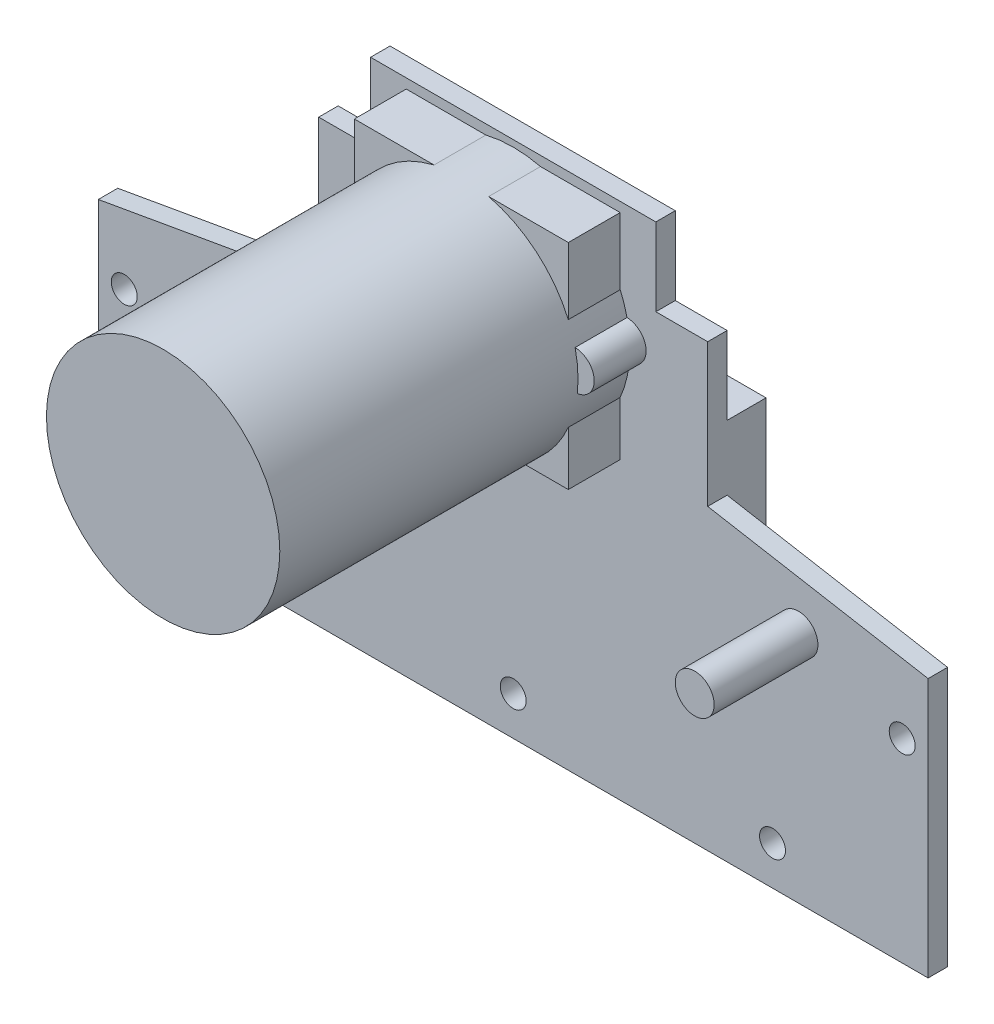
from build123d import *

# Parameters (mm, degrees)
SKETCH1_W           = 30
SKETCH1_H           = 11
SKETCH1_W_2         = 22
SKETCH1_H_2         = 6
BOSS_EXTRUDE1_DEPTH = 1.5
SKETCH2_R           = 1
CUT_EXTRUDE1_DEPTH  = 5
SKETCH3_R           = 9
BOSS_EXTRUDE2_DEPTH = 27
SKETCH5_W           = 28
SKETCH5_H           = 21
BOSS_EXTRUDE3_DEPTH = 3
SKETCH6_R           = 1.5
BOSS_EXTRUDE4_DEPTH = 8
SKETCH7_R           = 1.5
SKETCH7_W           = 16.5
SKETCH7_H           = 16.5
BOSS_EXTRUDE5_DEPTH = 4


with BuildPart() as part:
    # Sketch1 → Boss-Extrude1 (new body)
    with BuildSketch(Plane.XY):
        Polygon((32, 0), (32, 20), (15, 23), (-15, 23), (-32, 20), (-32, 0), align=None)
        with Locations((0, 28.5)):
            Rectangle(SKETCH1_W, SKETCH1_H)
        with Locations((0, 37)):
            Rectangle(SKETCH1_W_2, SKETCH1_H_2)
    extrude(amount=BOSS_EXTRUDE1_DEPTH)

    # Sketch2 → Cut-Extrude1 (cut)
    with BuildSketch(Plane.XY.offset(1.5)):
        with Locations((20, 3)):
            Circle(SKETCH2_R)
        with Locations((0, 3)):
            Circle(SKETCH2_R)
        with Locations((-20, 3)):
            Circle(SKETCH2_R)
        with Locations((-30, 15)):
            Circle(SKETCH2_R)
        with Locations((30, 15)):
            Circle(SKETCH2_R)
    extrude(amount=-CUT_EXTRUDE1_DEPTH, mode=Mode.SUBTRACT)

    # Sketch3 → Boss-Extrude2 (add)
    with BuildSketch(Plane.XY.offset(1.5)):
        with Locations((0, 30.5)):
            Circle(SKETCH3_R)
    extrude(amount=BOSS_EXTRUDE2_DEPTH)

    # Sketch5 → Boss-Extrude3 (add)
    with BuildSketch(Plane(origin=(0, 0, 0), x_dir=(-1, 0, 0), z_dir=(0, 0, -1))):
        with Locations((-1, 17.5)):
            Rectangle(SKETCH5_W, SKETCH5_H)
    extrude(amount=BOSS_EXTRUDE3_DEPTH)

    # Sketch6 → Boss-Extrude4 (add)
    with BuildSketch(Plane.XY.offset(1.5)):
        with Locations((22, 18)):
            Circle(SKETCH6_R)
        with Locations((-22, 18)):
            Circle(SKETCH6_R)
    extrude(amount=BOSS_EXTRUDE4_DEPTH)

    # Sketch7 → Boss-Extrude5 (add)
    with BuildSketch(Plane.XY.offset(1.5)):
        with Locations((-8.75, 31)):
            Circle(SKETCH7_R)
        with Locations((8.75, 31)):
            Circle(SKETCH7_R)
        with Locations((0, 31)):
            Rectangle(SKETCH7_W, SKETCH7_H)
    extrude(amount=BOSS_EXTRUDE5_DEPTH)


solid = part.part
